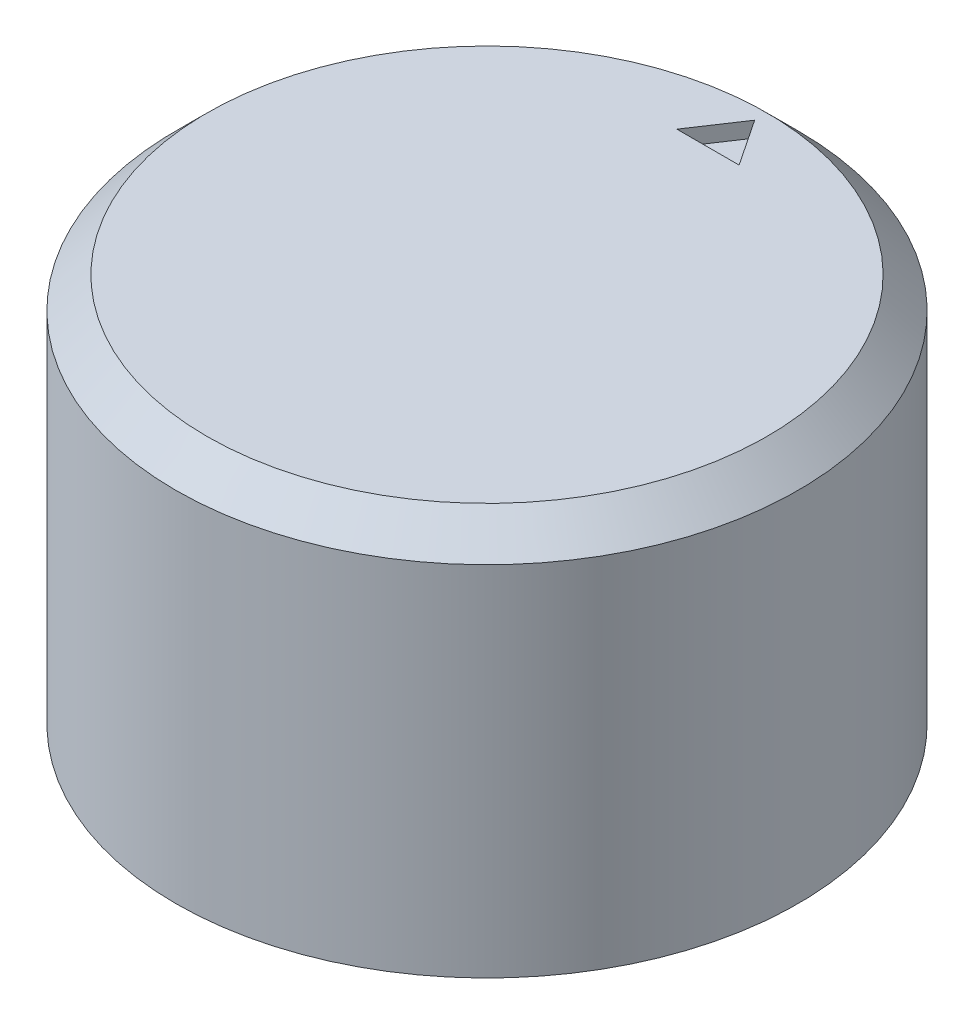
from build123d import *

# Parameters (mm, degrees)
SKETCH1_R           = 10
BOSS_EXTRUDE1_DEPTH = 12.5
CUT_EXTRUDE1_DEPTH  = 10
CUT_EXTRUDE2_DEPTH  = 0.5
CHAMFER1_SIZE       = 1


with BuildPart() as part:
    # Sketch1 → Boss-Extrude1 (new body)
    with BuildSketch(Plane(origin=(0, 0, 0), x_dir=(1, 0, 0), z_dir=(0, 1, 0))):
        Circle(SKETCH1_R)
    extrude(amount=BOSS_EXTRUDE1_DEPTH)

    # Sketch2 → Cut-Extrude1 (cut)
    with BuildSketch(Plane.XZ):
        with BuildLine():
            Line((-2.598076211, 1.5), (2.598076211, 1.5))
            ThreePointArc((2.598076211, 1.5), (0, -3), (-2.598076211, 1.5))
        make_face()
    extrude(amount=-CUT_EXTRUDE1_DEPTH, mode=Mode.SUBTRACT)

    # Sketch3 → Cut-Extrude2 (cut)
    with BuildSketch(Plane(origin=(0, 12.5, 0), x_dir=(1, 0, 0), z_dir=(0, 1, 0))):
        Polygon((-1, 7.1), (0, 8.6), (1, 7.1), align=None)
    extrude(amount=-CUT_EXTRUDE2_DEPTH, mode=Mode.SUBTRACT)

    # Chamfer1
    chamfer1_edges = [part.edges().sort_by_distance(p)[0] for p in [
        (-10, 12.5, 0),
    ]]
    chamfer(chamfer1_edges, length=CHAMFER1_SIZE)


solid = part.part
